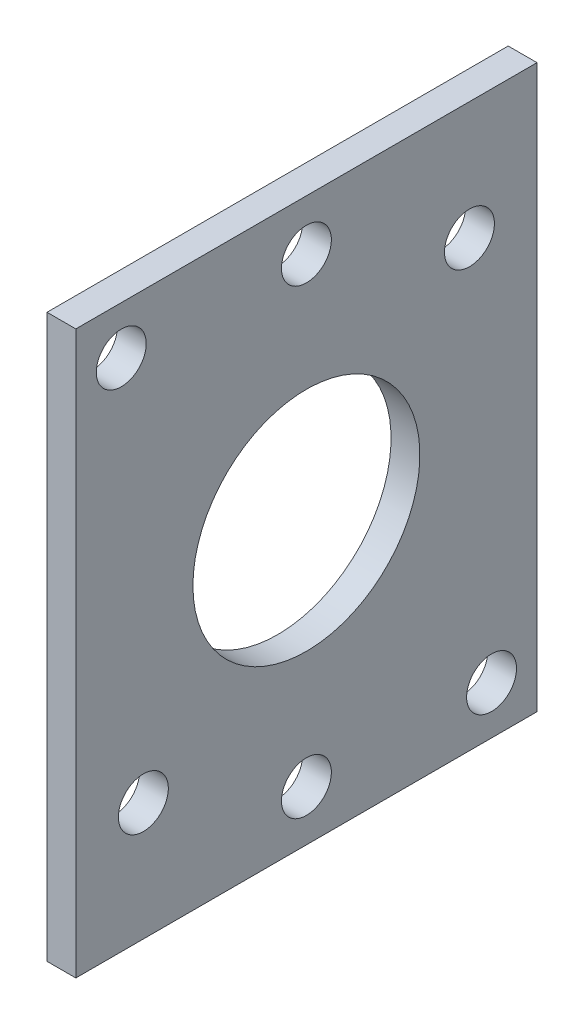
from build123d import *

# Parameters (mm, degrees)
SKETCH1_W           = 50.8
SKETCH1_H           = 61.92
BOSS_EXTRUDE2_DEPTH = 3.175
SKETCH2_R           = 2.75
SKETCH2_R_2         = 12.5
CUT_EXTRUDE1_DEPTH  = 4.175


with BuildPart() as part:
    # Sketch1 → Boss-Extrude2 (new body)
    with BuildSketch(Plane(origin=(0, 0, 0), x_dir=(0, 0, -1), z_dir=(1, 0, 0))):
        with Locations((25.4, 30.96)):
            Rectangle(SKETCH1_W, SKETCH1_H)
    extrude(amount=BOSS_EXTRUDE2_DEPTH)

    # Sketch2 → Cut-Extrude1 (cut, through all)
    with BuildSketch(Plane.ZY):
        with Locations((-25.399655405, 56.36)):
            Circle(SKETCH2_R)
        with Locations((-43.35992398, 48.920755906)):
            Circle(SKETCH2_R)
        with Locations((-5.004504526, 56.648087135)):
            Circle(SKETCH2_R)
        with Locations((-7.439487758, 13.000182758)):
            Circle(SKETCH2_R)
        with Locations((-45.795509398, 5.272471121)):
            Circle(SKETCH2_R)
        with Locations((-25.399655405, 5.560695)):
            Circle(SKETCH2_R)
        with Locations((-25.399655405, 30.96)):
            Circle(SKETCH2_R_2)
    extrude(amount=-CUT_EXTRUDE1_DEPTH, mode=Mode.SUBTRACT)


solid = part.part
